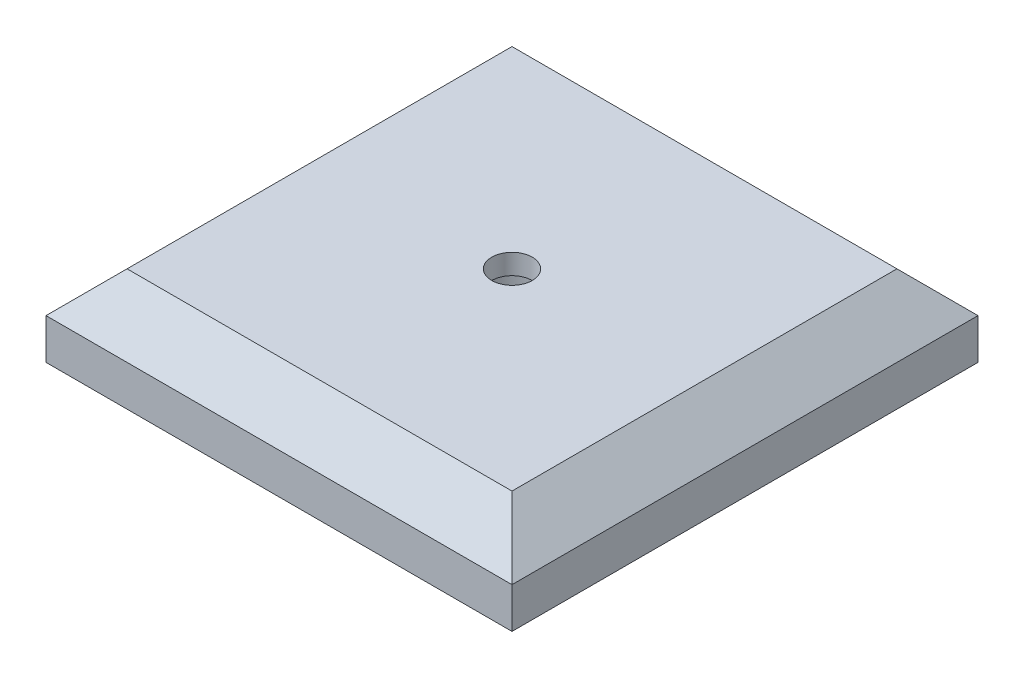
from build123d import *

# Parameters (mm, degrees)
SKETCH2_W           = 73.025
SKETCH2_H           = 73.025
BOSS_EXTRUDE1_DEPTH = 12.7
SKETCH3_R           = 3.175
CUT_EXTRUDE1_DEPTH  = 3.175
SKETCH4_R           = 6.35
CUT_EXTRUDE2_DEPTH  = 9.525
CHAMFER2_SIZE       = 6.35


with BuildPart() as part:
    # Sketch2 → Boss-Extrude1 (new body)
    with BuildSketch(Plane(origin=(0, 0, 0), x_dir=(1, 0, 0), z_dir=(0, 1, 0))):
        Rectangle(SKETCH2_W, SKETCH2_H)
    extrude(amount=BOSS_EXTRUDE1_DEPTH)

    # Sketch3 → Cut-Extrude1 (cut)
    with BuildSketch(Plane(origin=(0, 12.7, 0), x_dir=(1, 0, 0), z_dir=(0, 1, 0))):
        Circle(SKETCH3_R)
    extrude(amount=-CUT_EXTRUDE1_DEPTH, mode=Mode.SUBTRACT)

    # Sketch4 → Cut-Extrude2 (cut)
    with BuildSketch(Plane.XZ):
        Circle(SKETCH4_R)
    extrude(amount=-CUT_EXTRUDE2_DEPTH, mode=Mode.SUBTRACT)

    # Chamfer2
    chamfer2_edges = [part.edges().sort_by_distance(p)[0] for p in [
        (-36.5125, 12.7, 0),
        (0, 12.7, 36.5125),
        (36.5125, 12.7, 0),
        (0, 12.7, -36.5125),
    ]]
    chamfer(chamfer2_edges, length=CHAMFER2_SIZE)


solid = part.part
